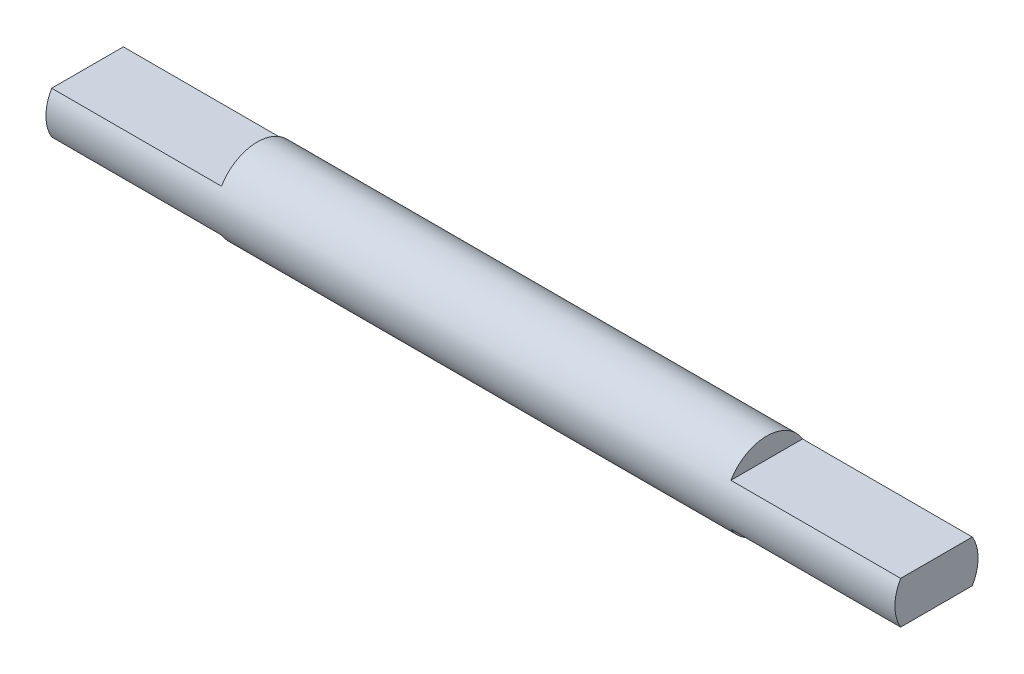
from build123d import *

# Parameters (mm, degrees)
SKETCH1_R           = 2.45
BOSS_EXTRUDE1_DEPTH = 50
CUT_EXTRUDE1_DEPTH  = 10
CUT_EXTRUDE2_START  = -50
CUT_EXTRUDE2_DEPTH  = 10


with BuildPart() as part:
    # Sketch1 → Boss-Extrude1 (new body)
    with BuildSketch(Plane(origin=(0, 0, 0), x_dir=(0, 0, -1), z_dir=(1, 0, 0))):
        Circle(SKETCH1_R)
    extrude(amount=BOSS_EXTRUDE1_DEPTH)

    # Sketch2 → Cut-Extrude1 (cut)
    with BuildSketch(Plane(origin=(50, 0, 0), x_dir=(0, 0, -1), z_dir=(1, 0, 0))):
        with BuildLine():
            Line((-2.110088861, 1.245), (2.110088861, 1.245))
            ThreePointArc((2.110088861, 1.245), (0, 2.45), (-2.110088861, 1.245))
        make_face()
        with BuildLine():
            Line((-2.110088861, -1.245), (2.110088861, -1.245))
            ThreePointArc((2.110088861, -1.245), (0, -2.45), (-2.110088861, -1.245))
        make_face()
    extrude(amount=-CUT_EXTRUDE1_DEPTH, mode=Mode.SUBTRACT)

    # Sketch2_2 → Cut-Extrude2 (cut)
    with BuildSketch(Plane(origin=(50, 0, 0), x_dir=(0, 0, -1), z_dir=(1, 0, 0)).offset(CUT_EXTRUDE2_START)):
        with BuildLine():
            Line((-2.110088861, 1.245), (2.110088861, 1.245))
            ThreePointArc((2.110088861, 1.245), (0, 2.45), (-2.110088861, 1.245))
        make_face()
        with BuildLine():
            Line((-2.110088861, -1.245), (2.110088861, -1.245))
            ThreePointArc((2.110088861, -1.245), (0, -2.45), (-2.110088861, -1.245))
        make_face()
    extrude(amount=CUT_EXTRUDE2_DEPTH, mode=Mode.SUBTRACT)


solid = part.part
